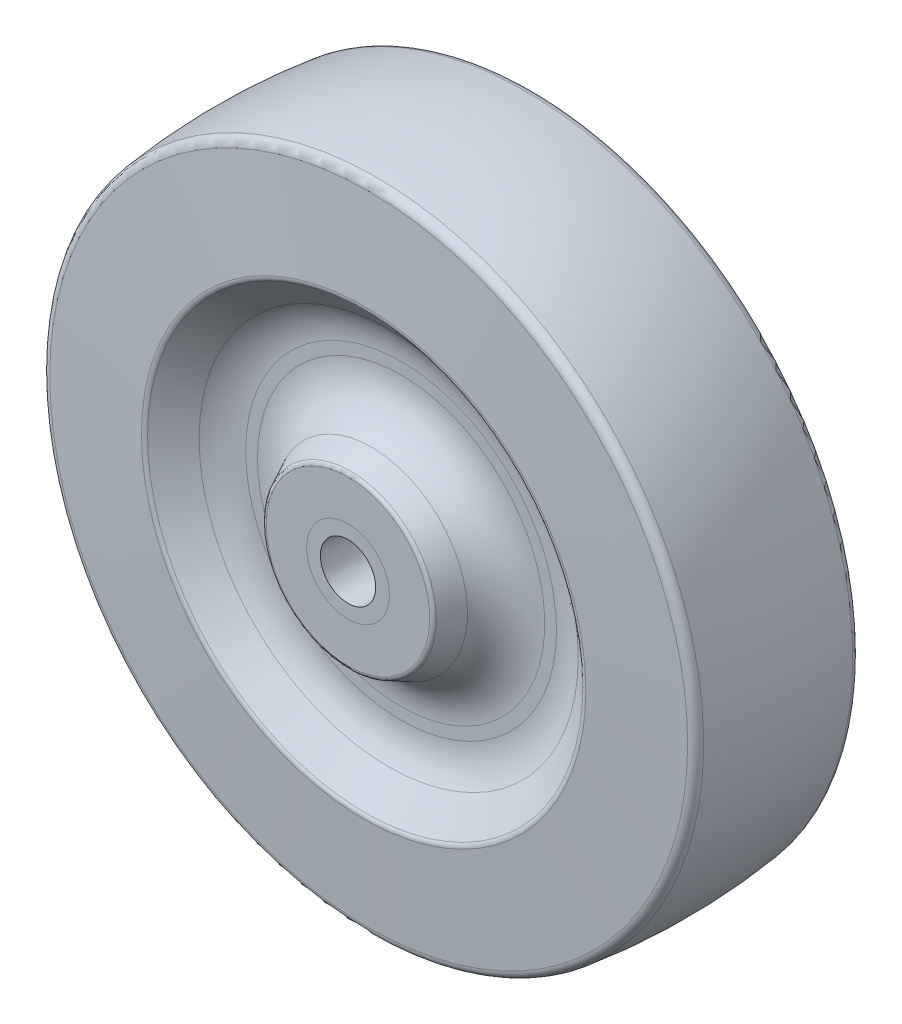
from build123d import *

# Parameters (mm, degrees)
SKETCH3_W               = 23.6474
SKETCH3_H               = 4.7498
SKETCH6_W               = 23.6474
SKETCH6_H               = 4.7498
CUT_EXTRUDE1_DEPTH      = 56.163574004
CUT_EXTRUDE1_DEPTH_BACK = 56.163574004
SKETCH4_R               = 3.175
FILLET1_R               = 1.016
FILLET2_R               = 6.096
FILLET3_R               = 0.762
FILLET4_R               = 0.508


with BuildPart() as part:
    # Sketch2 → Revolve1 (revolve)
    with BuildSketch(Plane(origin=(0, 0, 0), x_dir=(0, 0, -1), z_dir=(1, 0, 0))):
        with BuildLine():
            Line((10.0457, 25.211992013), (5.7277, 20.066))
            Line((5.7277, 20.066), (5.7277, 12.7))
            Line((5.7277, 12.7), (11.8237, 9.7028))
            Line((11.8237, 9.7028), (11.8237, 0))
            Line((11.8237, 0), (-11.8237, 0))
            Line((-11.8237, 0), (-11.8237, 9.7028))
            Line((-11.8237, 9.7028), (-5.7277, 12.7))
            Line((-5.7277, 12.7), (-5.7277, 20.066))
            Line((-5.7277, 20.066), (-10.0457, 25.211992013))
            Line((-10.0457, 25.211992013), (-9.403592979, 37.464123841))
            ThreePointArc((-9.403592979, 37.464123841), (0, 38.1), (9.403592979, 37.464123841))
            Line((9.403592979, 37.464123841), (10.0457, 25.211992013))
        make_face()
    revolve(axis=Axis((0, 0, 11.8237), (0, 0, -1)))

    # Sketch6 → Cut-Revolve1 (revolve, cut)
    with BuildSketch(Plane(origin=(0, 0, 0), x_dir=(0, 0, -1), z_dir=(1, 0, 0))):
        with Locations((0, 2.3749)):
            Rectangle(SKETCH6_W, SKETCH6_H)
    revolve(axis=Axis((0, 0, 11.8237), (0, 0, -1)), mode=Mode.SUBTRACT)

    # Fillet1
    fillet1_edges = [part.edges().sort_by_distance(p)[0] for p in [
        (0, -37.464123841, 9.403592979),
        (0, -37.464123841, -9.403592979),
    ]]
    fillet(fillet1_edges, radius=FILLET1_R)

    # Fillet2
    fillet2_edges = [part.edges().sort_by_distance(p)[0] for p in [
        (0, -20.066, -5.7277),
        (0, -12.7, -5.7277),
        (0, -12.7, 5.7277),
        (0, -20.066, 5.7277),
    ]]
    fillet(fillet2_edges, radius=FILLET2_R)

    # Fillet3
    fillet3_edges = [part.edges().sort_by_distance(p)[0] for p in [
        (0, -25.211992013, 10.0457),
        (0, -25.211992013, -10.0457),
    ]]
    fillet(fillet3_edges, radius=FILLET3_R)

    # Fillet4
    fillet4_edges = [part.edges().sort_by_distance(p)[0] for p in [
        (0, -9.7028, -11.8237),
        (0, -9.7028, 11.8237),
    ]]
    fillet(fillet4_edges, radius=FILLET4_R)


with BuildPart() as body_2:
    # Sketch3 → Revolve2 (revolve)
    with BuildSketch(Plane(origin=(0, 0, 0), x_dir=(0, 0, -1), z_dir=(1, 0, 0))):
        with Locations((0, 2.3749)):
            Rectangle(SKETCH3_W, SKETCH3_H)
    revolve(axis=Axis((0, 0, 11.8237), (0, 0, -1)))

    # Sketch4 → Cut-Extrude1 (cut, two sides: drawn at the far end of the back side and taken through both)
    with BuildSketch(Plane.XY.offset(-CUT_EXTRUDE1_DEPTH_BACK)):
        Circle(SKETCH4_R)
    extrude(amount=CUT_EXTRUDE1_DEPTH + CUT_EXTRUDE1_DEPTH_BACK, mode=Mode.SUBTRACT)


solid = Compound([part.part, body_2.part])
